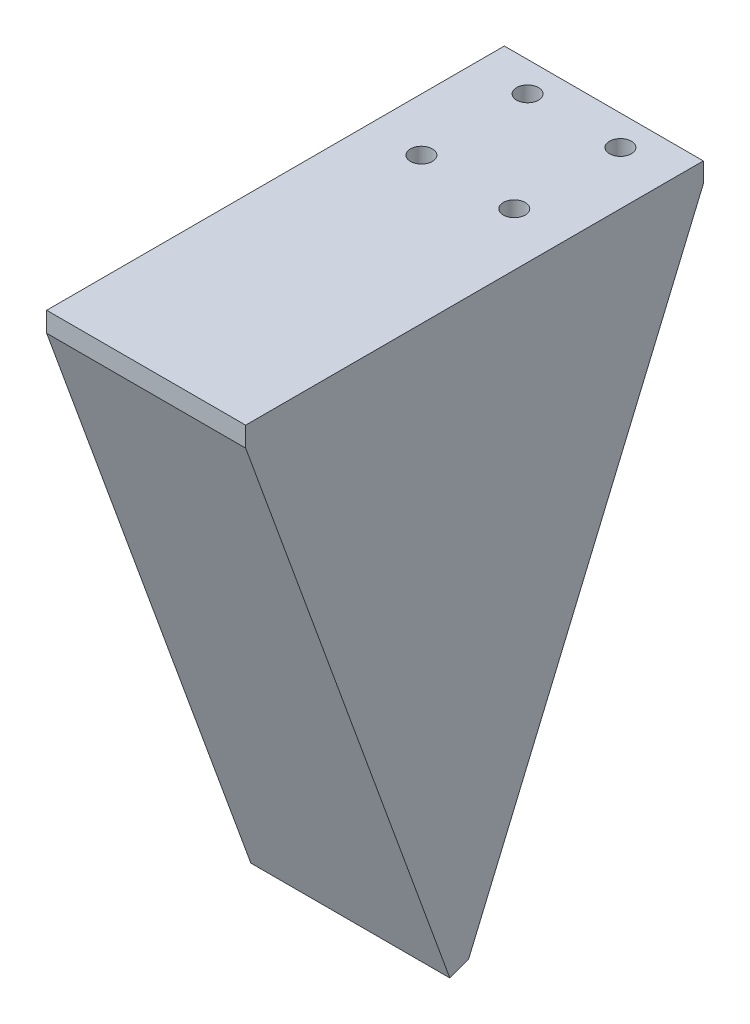
from build123d import *

# Parameters (mm, degrees)
BOSS_EXTRUDE1_DEPTH = 3
SKETCH2_R           = 1.65
CUT_EXTRUDE1_DEPTH  = 4
SKETCH3_W           = 30
SKETCH3_H           = 3
BOSS_EXTRUDE2_DEPTH = 8
BOSS_EXTRUDE3_DEPTH = 30
BOSS_EXTRUDE4_DEPTH = 3


with BuildPart() as part:
    # Sketch1 → Boss-Extrude1 (new body)
    with BuildSketch(Plane(origin=(0, 0, 0), x_dir=(1, 0, 0), z_dir=(0, 1, 0))):
        Polygon((15, -28), (15, 30), (-15, 30), (-15, -28), (-15, -31), (15, -31), align=None)
    extrude(amount=BOSS_EXTRUDE1_DEPTH)

    # Sketch2 → Cut-Extrude1 (cut)
    with BuildSketch(Plane(origin=(0, 3, 0), x_dir=(1, 0, 0), z_dir=(0, 1, 0))):
        with Locations((-7, 25.5)):
            Circle(SKETCH2_R)
        with Locations((7, 25.5)):
            Circle(SKETCH2_R)
        with Locations((-7, 9.5)):
            Circle(SKETCH2_R)
        with Locations((7, 9.5)):
            Circle(SKETCH2_R)
    extrude(amount=-CUT_EXTRUDE1_DEPTH, mode=Mode.SUBTRACT)

    # Sketch3 → Boss-Extrude2 (add)
    with BuildSketch(Plane.XY.offset(31)):
        with Locations((0, 1.5)):
            Rectangle(SKETCH3_W, SKETCH3_H)
    extrude(amount=BOSS_EXTRUDE2_DEPTH)

    # Sketch5 → Boss-Extrude3 (add)
    with BuildSketch(Plane.ZY.offset(15)):
        Polygon((39, 0), (8.218187101, -84.572335871), (5.399109238, -83.546275441), (35.807466683, 0), align=None)
    extrude(amount=-BOSS_EXTRUDE3_DEPTH)

    # Sketch6 → Boss-Extrude4 (add)
    with BuildSketch(Plane(origin=(15, 0, 0), x_dir=(0, 0, -1), z_dir=(1, 0, 0))):
        Polygon((30, 0), (-5.399109238, -83.546275441), (-8.218187101, -84.572335871), (-39, 0), (-39, 3), (30, 3), align=None)
    extrude(amount=-BOSS_EXTRUDE4_DEPTH)


solid = part.part
